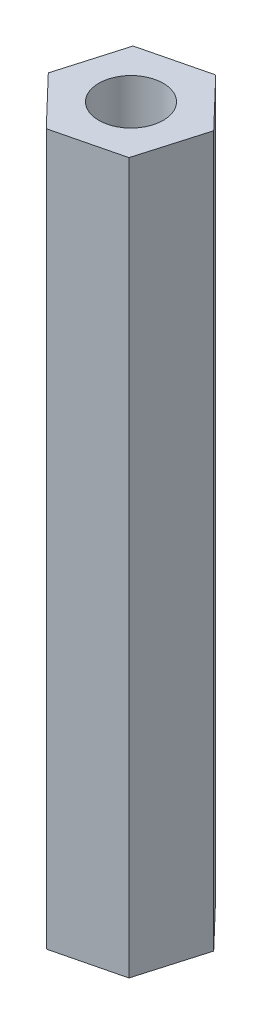
from build123d import *

# Parameters (mm, degrees)
BOSS_EXTRUDE1_DEPTH = 38.1
SKETCH2_R           = 1.7272
CUT_EXTRUDE1_DEPTH  = 9.525
SKETCH3_R           = 1.7272
CUT_EXTRUDE2_DEPTH  = 9.525


with BuildPart() as part:
    # Sketch1 → Boss-Extrude1 (new body)
    with BuildSketch(Plane(origin=(0, 0, 0), x_dir=(1, 0, 0), z_dir=(0, 1, 0))):
        Polygon((-2.767735883, 3.334911674), (-1.744793251, 6.855482892), (-4.282226046, 9.501662807), (-7.842601473, 8.627271504), (-8.865544105, 5.106700285), (-6.32811131, 2.46052037), align=None)
    extrude(amount=BOSS_EXTRUDE1_DEPTH)

    # Sketch2 → Cut-Extrude1 (cut)
    with BuildSketch(Plane(origin=(0, 38.1, 0), x_dir=(1, 0, 0), z_dir=(0, 1, 0))):
        with Locations((-5.305168678, 5.981091589)):
            Circle(SKETCH2_R)
    extrude(amount=-CUT_EXTRUDE1_DEPTH, mode=Mode.SUBTRACT)

    # Sketch3 → Cut-Extrude2 (cut)
    with BuildSketch(Plane.XZ):
        with Locations((-5.305168678, -5.981091589)):
            Circle(SKETCH3_R)
    extrude(amount=-CUT_EXTRUDE2_DEPTH, mode=Mode.SUBTRACT)


solid = part.part
